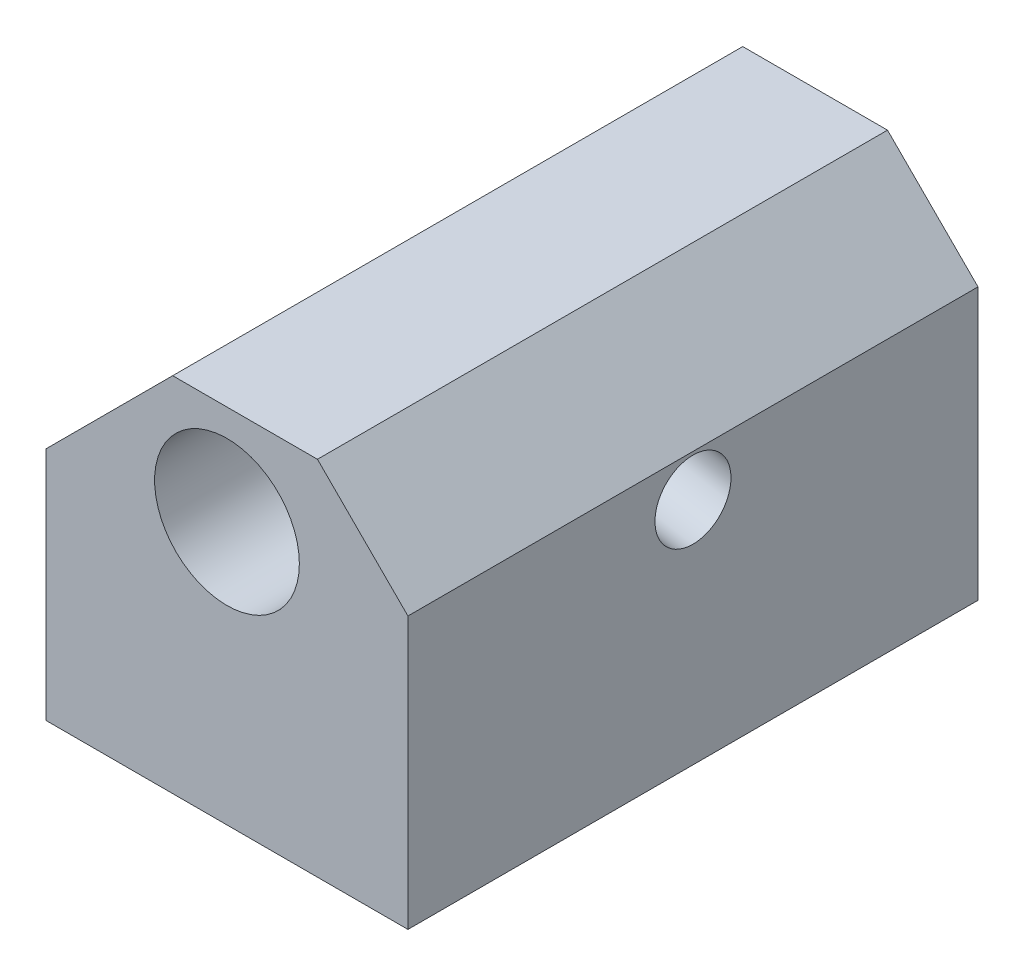
from build123d import *

# Parameters (mm, degrees)
ESQUISSE1_R            = 4
BOSS_EXTRU_1_DEPTH     = 15.75
TROU_TARAUD_M101_D     = 8.5
TROU_TARAUD_M101_DEPTH = 15
TROU_TARAUD_M101_TIP   = 2.553657631
TROU_TARAUD_M51_D      = 4.2
TROU_TARAUD_M51_DEPTH  = 10
TROU_TARAUD_M51_TIP    = 1.2618073


with BuildPart() as part:
    # Esquisse1 → Boss.-Extru.1 (new body, symmetric)
    with BuildSketch(Plane.XY):
        Polygon((-10, 3), (-10, -10), (10, -10), (10, 5), (5, 10), (-3, 10), align=None)
        with Locations((0, 4.5)):
            Circle(ESQUISSE1_R, mode=Mode.SUBTRACT)
    extrude(amount=BOSS_EXTRU_1_DEPTH, both=True)

    # Trou taraudé M101
    with Locations(Plane(origin=(0, -10, 0), x_dir=(-1, 0, 0), z_dir=(0, -1, 0))):
        with Locations((0, 0)):
            Hole(TROU_TARAUD_M101_D / 2, depth=TROU_TARAUD_M101_DEPTH)
            with Locations((0, 0, -(TROU_TARAUD_M101_DEPTH + TROU_TARAUD_M101_TIP / 2))):  # 118° drill point
                Cone(0, TROU_TARAUD_M101_D / 2, TROU_TARAUD_M101_TIP, mode=Mode.SUBTRACT)

    # Trou taraudé M51
    with Locations(Plane(origin=(11.408563821, -2.011637613, 0), x_dir=(0, 0, -1), z_dir=(0.984807753, -0.173648178, 0))):
        with Locations((0, 4.388404247)):
            Hole(TROU_TARAUD_M51_D / 2, depth=TROU_TARAUD_M51_DEPTH)
            with Locations((0, 0, -(TROU_TARAUD_M51_DEPTH + TROU_TARAUD_M51_TIP / 2))):  # 118° drill point
                Cone(0, TROU_TARAUD_M51_D / 2, TROU_TARAUD_M51_TIP, mode=Mode.SUBTRACT)


solid = part.part
